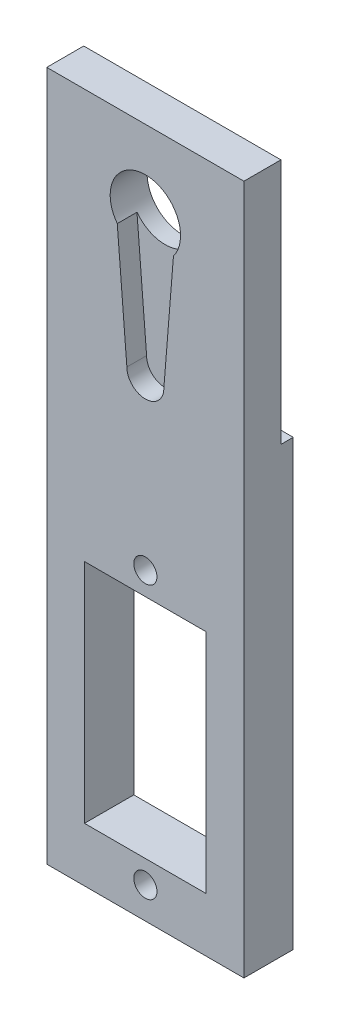
from build123d import *

# Parameters (mm, degrees)
SKETCH3_W           = 20
SKETCH3_H           = 70
BOSS_EXTRUDE3_DEPTH = 5
CUT_EXTRUDE2_DEPTH  = 2
SKETCH6_R           = 3.57
CUT_EXTRUDE3_DEPTH  = 3
SKETCH7_R           = 1.175
SKETCH7_W           = 12.35
SKETCH7_H           = 23
CUT_EXTRUDE4_DEPTH  = 5
SKETCH8_W           = 1.25
SKETCH8_H           = 25
CUT_EXTRUDE5_DEPTH  = 30


with BuildPart() as part:
    # Sketch3 → Boss-Extrude3 (new body)
    with BuildSketch(Plane.XY):
        Rectangle(SKETCH3_W, SKETCH3_H)
    extrude(amount=BOSS_EXTRUDE3_DEPTH)

    # Sketch4 → Cut-Extrude2 (cut)
    with BuildSketch(Plane.XY.offset(5)):
        with BuildLine():
            Line((-2.85, 24.850023256), (-1.875, 12.739206809))
            Line((-1.875, 12.739206809), (1.875, 12.739206809))
            Line((1.875, 12.739206809), (2.85, 24.850023256))
            ThreePointArc((2.85, 24.850023256), (0, 23.43), (-2.85, 24.850023256))
        make_face()
        with BuildLine():
            Line((1.875, 12.739206809), (-1.875, 12.739206809))
            ThreePointArc((-1.875, 12.739206809), (0, 10.864206809), (1.875, 12.739206809))
        make_face()
        with BuildLine():
            ThreePointArc((3.57, 27), (-1.133666618, 30.385217866), (-2.85, 24.850023256))
            Line((-2.85, 24.850023256), (2.85, 24.850023256))
            ThreePointArc((2.85, 24.850023256), (3.385217866, 25.866333382), (3.57, 27))
        make_face()
        with BuildLine():
            Line((2.85, 24.850023256), (-2.85, 24.850023256))
            ThreePointArc((-2.85, 24.850023256), (0, 23.43), (2.85, 24.850023256))
        make_face()
    extrude(amount=-CUT_EXTRUDE2_DEPTH, mode=Mode.SUBTRACT)

    # Sketch6 → Cut-Extrude3 (cut)
    with BuildSketch(Plane.XY.offset(3)):
        with Locations((0, 27)):
            Circle(SKETCH6_R)
    extrude(amount=-CUT_EXTRUDE3_DEPTH, mode=Mode.SUBTRACT)

    # Sketch7 → Cut-Extrude4 (cut)
    with BuildSketch(Plane.XY.offset(5)):
        with Locations((0, -4.18)):
            Circle(SKETCH7_R)
        with Locations((0, -31.82)):
            Circle(SKETCH7_R)
        with Locations((0, -18)):
            Rectangle(SKETCH7_W, SKETCH7_H)
    extrude(amount=-CUT_EXTRUDE4_DEPTH, mode=Mode.SUBTRACT)

    # Sketch8 → Cut-Extrude5 (cut)
    with BuildSketch(Plane(origin=(10, 0, 0), x_dir=(0, 0, -1), z_dir=(1, 0, 0))):
        with Locations((-0.625, 22.5)):
            Rectangle(SKETCH8_W, SKETCH8_H)
    extrude(amount=-CUT_EXTRUDE5_DEPTH, mode=Mode.SUBTRACT)


solid = part.part
